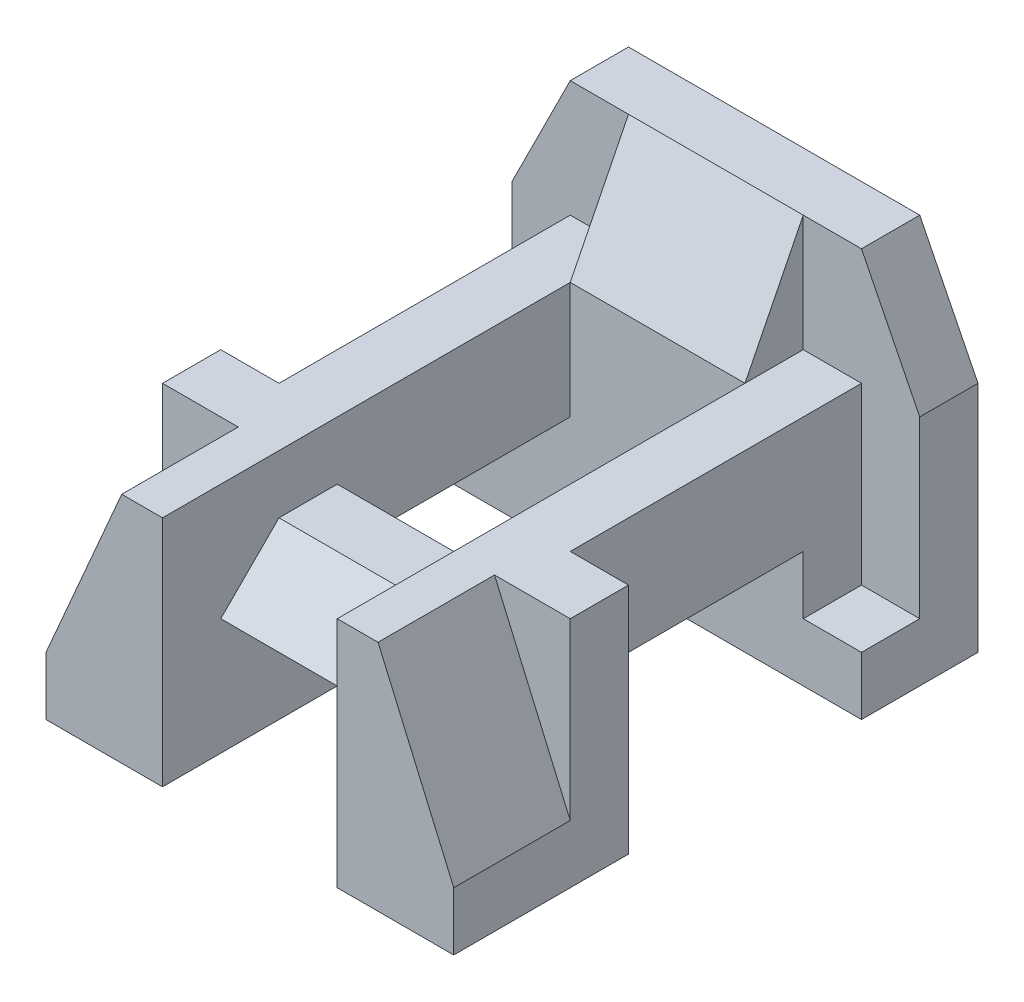
from build123d import *

# Parameters (mm, degrees)
SKETCH1_W           = 7
SKETCH1_H           = 6
BOSS_EXTRUDE1_DEPTH = 9
SKETCH2_W           = 3
SKETCH2_H           = 1
CUT_EXTRUDE10_DEPTH = 7
CUT_EXTRUDE11_DEPTH = 1
SKETCH12_W          = 1
SKETCH12_H          = 1
CUT_EXTRUDE12_DEPTH = 5
SKETCH13_W          = 1
SKETCH13_H          = 4
CUT_EXTRUDE13_DEPTH = 7
CUT_EXTRUDE14_DEPTH = 2
SKETCH15_W          = 3
SKETCH15_H          = 2
CUT_EXTRUDE17_DEPTH = 6
SKETCH18_W          = 3
SKETCH18_H          = 1
CUT_EXTRUDE18_DEPTH = 6
SKETCH20_W          = 3
SKETCH20_H          = 3.16227766
CUT_EXTRUDE19_DEPTH = 6
SKETCH21_W          = 3
SKETCH21_H          = 4
CUT_EXTRUDE20_DEPTH = 6
SKETCH22_W          = 3
SKETCH22_H          = 1
CUT_EXTRUDE22_DEPTH = 6
SKETCH23_W          = 7
SKETCH23_H          = 2
CUT_EXTRUDE24_DEPTH = 7
SKETCH24_W          = 3
SKETCH24_H          = 1
CUT_EXTRUDE25_DEPTH = 2
SKETCH25_W          = 3
SKETCH25_H          = 1
CUT_EXTRUDE26_DEPTH = 2
SKETCH28_W          = 3
SKETCH28_H          = 2.236067977
CUT_EXTRUDE27_DEPTH = 2
SKETCH29_W          = 1
SKETCH29_H          = 2
CUT_EXTRUDE28_DEPTH = 1
SKETCH30_W          = 1
SKETCH30_H          = 2
CUT_EXTRUDE29_DEPTH = 1
SKETCH31_W          = 3
SKETCH31_H          = 2
CUT_EXTRUDE30_DEPTH = 40
CUT_EXTRUDE31_DEPTH = 3


with BuildPart() as part:
    # Sketch1 → Boss-Extrude1 (new body)
    with BuildSketch(Plane.XY):
        Rectangle(SKETCH1_W, SKETCH1_H)
    extrude(amount=BOSS_EXTRUDE1_DEPTH)

    # Sketch2 → Cut-Extrude10 (cut, through all)
    with BuildSketch(Plane(origin=(0, 3, 0), x_dir=(1, 0, 0), z_dir=(0, 1, 0))):
        with Locations((0, -8.5)):
            Rectangle(SKETCH2_W, SKETCH2_H)
    extrude(amount=-CUT_EXTRUDE10_DEPTH, mode=Mode.SUBTRACT)

    # Sketch11 → Cut-Extrude11 (cut)
    with BuildSketch(Plane(origin=(0, 0, 0), x_dir=(-1, 0, 0), z_dir=(0, 0, -1))):
        Polygon((-2.5, 3), (-3.5, 1), (-3.5, 3), align=None)
        Polygon((3.5, 3), (2.5, 3), (3.5, 1), align=None)
    extrude(amount=-CUT_EXTRUDE11_DEPTH, mode=Mode.SUBTRACT)

    # Sketch12 → Cut-Extrude12 (cut)
    with BuildSketch(Plane(origin=(0, 3, 0), x_dir=(1, 0, 0), z_dir=(0, 1, 0))):
        with Locations((3, -1.5)):
            Rectangle(SKETCH12_W, SKETCH12_H)
        with Locations((-3, -1.5)):
            Rectangle(SKETCH12_W, SKETCH12_H)
    extrude(amount=-CUT_EXTRUDE12_DEPTH, mode=Mode.SUBTRACT)

    # Sketch13 → Cut-Extrude13 (cut, through all)
    with BuildSketch(Plane(origin=(0, 3, 0), x_dir=(1, 0, 0), z_dir=(0, 1, 0))):
        with Locations((3, -4)):
            Rectangle(SKETCH13_W, SKETCH13_H)
        with Locations((-3, -4)):
            Rectangle(SKETCH13_W, SKETCH13_H)
    extrude(amount=-CUT_EXTRUDE13_DEPTH, mode=Mode.SUBTRACT)

    # Sketch14 → Cut-Extrude14 (cut)
    with BuildSketch(Plane.XY.offset(9)):
        Polygon((3.5, 3), (2.5, 3), (3.5, -2), align=None)
        Polygon((-3.5, 3), (-2.5, 3), (-3.5, -2), align=None)
    extrude(amount=-CUT_EXTRUDE14_DEPTH, mode=Mode.SUBTRACT)

    # Sketch15 → Cut-Extrude17 (cut)
    with BuildSketch(Plane.XY.offset(8)):
        with Locations((0, -2)):
            Rectangle(SKETCH15_W, SKETCH15_H)
    extrude(amount=-CUT_EXTRUDE17_DEPTH, mode=Mode.SUBTRACT)

    # Sketch18 → Cut-Extrude18 (cut)
    with BuildSketch(Plane.XY.offset(8)):
        with Locations((0, 2.5)):
            Rectangle(SKETCH18_W, SKETCH18_H)
    extrude(amount=-CUT_EXTRUDE18_DEPTH, mode=Mode.SUBTRACT)

    # Sketch20 → Cut-Extrude19 (cut)
    with BuildSketch(Plane(origin=(0, 2.3, 6.9), x_dir=(-1, 0, 0), z_dir=(0, -0.316227766, -0.948683298))):
        with Locations((0, -1.897366596)):
            Rectangle(SKETCH20_W, SKETCH20_H)
    extrude(amount=-CUT_EXTRUDE19_DEPTH, mode=Mode.SUBTRACT)

    # Sketch21 → Cut-Extrude20 (cut, through all)
    with BuildSketch(Plane(origin=(0, 2, 0), x_dir=(1, 0, 0), z_dir=(0, 1, 0))):
        with Locations((0, -4)):
            Rectangle(SKETCH21_W, SKETCH21_H)
    extrude(amount=-CUT_EXTRUDE20_DEPTH, mode=Mode.SUBTRACT)

    # Sketch22 → Cut-Extrude22 (cut)
    with BuildSketch(Plane.XY.offset(9)):
        with Locations((0, 1.5)):
            Rectangle(SKETCH22_W, SKETCH22_H)
    extrude(amount=-CUT_EXTRUDE22_DEPTH, mode=Mode.SUBTRACT)

    # Sketch23 → Cut-Extrude24 (cut)
    with BuildSketch(Plane.XY.offset(9)):
        with Locations((0, 2)):
            Rectangle(SKETCH23_W, SKETCH23_H)
    extrude(amount=-CUT_EXTRUDE24_DEPTH, mode=Mode.SUBTRACT)

    # Sketch24 → Cut-Extrude25 (cut)
    with BuildSketch(Plane.XY.offset(9)):
        Polygon((2.2, 1), (3.5, -2), (2.9, 1), align=None)
        Polygon((-2.2, 1), (-2.9, 1), (-3.5, -2), align=None)
        with Locations((0, 0.5)):
            Rectangle(SKETCH24_W, SKETCH24_H)
    extrude(amount=-CUT_EXTRUDE25_DEPTH, mode=Mode.SUBTRACT)

    # Sketch25 → Cut-Extrude26 (cut)
    with BuildSketch(Plane.XY.offset(7)):
        with Locations((0, 0.5)):
            Rectangle(SKETCH25_W, SKETCH25_H)
    extrude(amount=-CUT_EXTRUDE26_DEPTH, mode=Mode.SUBTRACT)

    # Sketch28 → Cut-Extrude27 (cut)
    with BuildSketch(Plane(origin=(0, 1, 2), x_dir=(1, 0, 0), z_dir=(0, 0.447213595, 0.894427191))):
        with Locations((0, 1.118033989)):
            Rectangle(SKETCH28_W, SKETCH28_H)
    extrude(amount=CUT_EXTRUDE27_DEPTH, mode=Mode.SUBTRACT)

    # Sketch29 → Cut-Extrude28 (cut)
    with BuildSketch(Plane(origin=(2.5, 0, 0), x_dir=(0, 0, -1), z_dir=(1, 0, 0))):
        with Locations((-1.5, 2)):
            Rectangle(SKETCH29_W, SKETCH29_H)
    extrude(amount=-CUT_EXTRUDE28_DEPTH, mode=Mode.SUBTRACT)

    # Sketch30 → Cut-Extrude29 (cut)
    with BuildSketch(Plane.ZY.offset(2.5)):
        with Locations((1.5, 2)):
            Rectangle(SKETCH30_W, SKETCH30_H)
    extrude(amount=-CUT_EXTRUDE29_DEPTH, mode=Mode.SUBTRACT)

    # Sketch31 → Cut-Extrude30 (cut)
    with BuildSketch(Plane(origin=(2.5, 0, 0), x_dir=(0, 0, -1), z_dir=(1, 0, 0))):
        with Locations((-3.5, -2)):
            Rectangle(SKETCH31_W, SKETCH31_H)
    extrude(amount=-CUT_EXTRUDE30_DEPTH, mode=Mode.SUBTRACT)

    # Sketch33 → Cut-Extrude31 (cut)
    with BuildSketch(Plane(origin=(-1.5, 0, 0), x_dir=(0, 0, -1), z_dir=(1, 0, 0))):
        Polygon((-7, 0), (-8, -1), (-8.435720839, 0.362085591), align=None)
    extrude(amount=CUT_EXTRUDE31_DEPTH, mode=Mode.SUBTRACT)


solid = part.part
